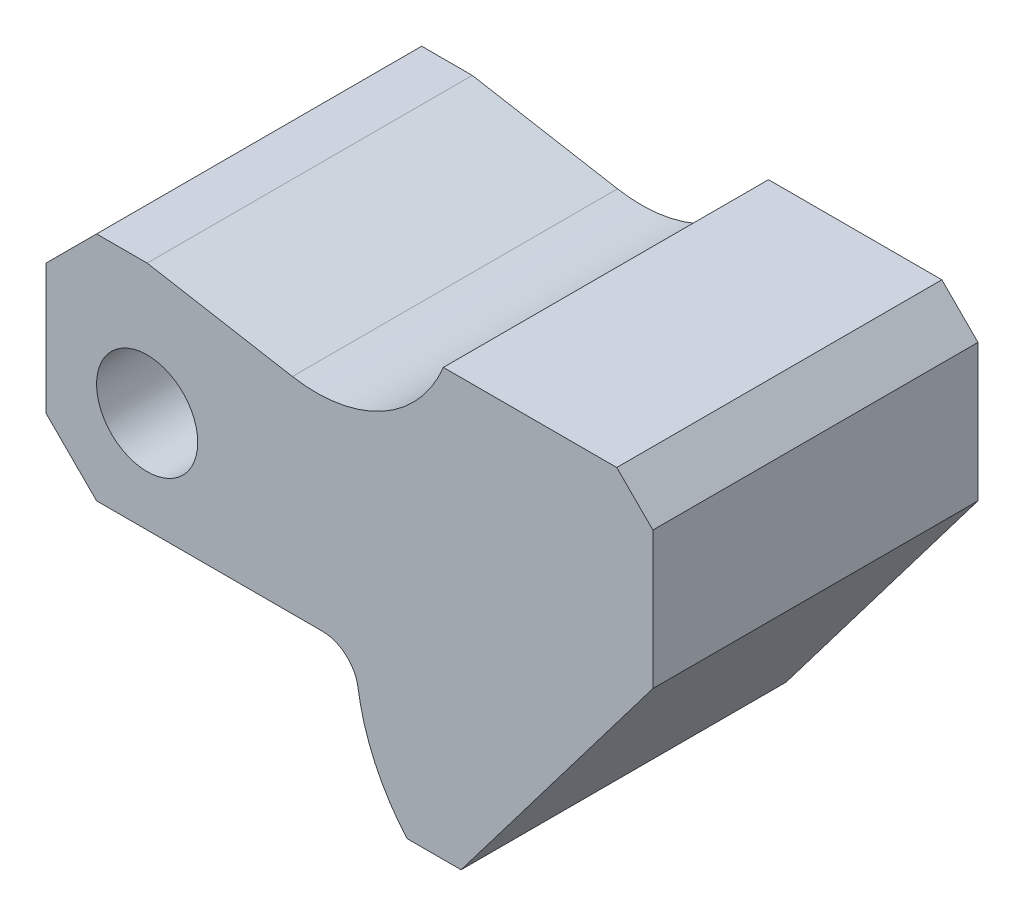
from build123d import *

# Parameters (mm, degrees)
SKETCH1_R           = 7
BOSS_EXTRUDE1_DEPTH = 45
CHAMFER1_SIZE       = 7
CHAMFER2_SIZE       = 7
CHAMFER3_SIZE       = 5
FILLET1_R           = 5


with BuildPart() as part:
    # Sketch1 → Boss-Extrude1 (new body)
    with BuildSketch(Plane.XY):
        with BuildLine():
            Line((14, 0), (0, 0))
            Line((0, 0), (0, -32))
            Line((0, -32), (42.863608631, -32))
            ThreePointArc((42.863608631, -32), (44.694157304, -42.140064899), (49.954706191, -51))
            Line((49.954706191, -51), (57.451644827, -51))
            Line((57.451644827, -51), (84, -16))
            Line((84, -16), (84, 8))
            Line((84, 8), (55, 8))
            ThreePointArc((55, 8), (46.591637328, -1.464097542), (34.104042352, -3.544885088))
            Line((34.104042352, -3.544885088), (14, 0))
        make_face()
        with Locations((14, -18)):
            Circle(SKETCH1_R, mode=Mode.SUBTRACT)
    extrude(amount=BOSS_EXTRUDE1_DEPTH)

    # Chamfer1
    chamfer1_edges = [part.edges().sort_by_distance(p)[0] for p in [
        (0, 0, 22.5),
    ]]
    chamfer(chamfer1_edges, length=CHAMFER1_SIZE)

    # Chamfer2
    chamfer2_edges = [part.edges().sort_by_distance(p)[0] for p in [
        (0, -32, 22.5),
    ]]
    chamfer(chamfer2_edges, length=CHAMFER2_SIZE)

    # Chamfer3
    chamfer3_edges = [part.edges().sort_by_distance(p)[0] for p in [
        (84, 8, 22.5),
    ]]
    chamfer(chamfer3_edges, length=CHAMFER3_SIZE)

    # Fillet1
    fillet1_edges = [part.edges().sort_by_distance(p)[0] for p in [
        (42.863608631, -32, 22.5),
    ]]
    fillet(fillet1_edges, radius=FILLET1_R)


solid = part.part
